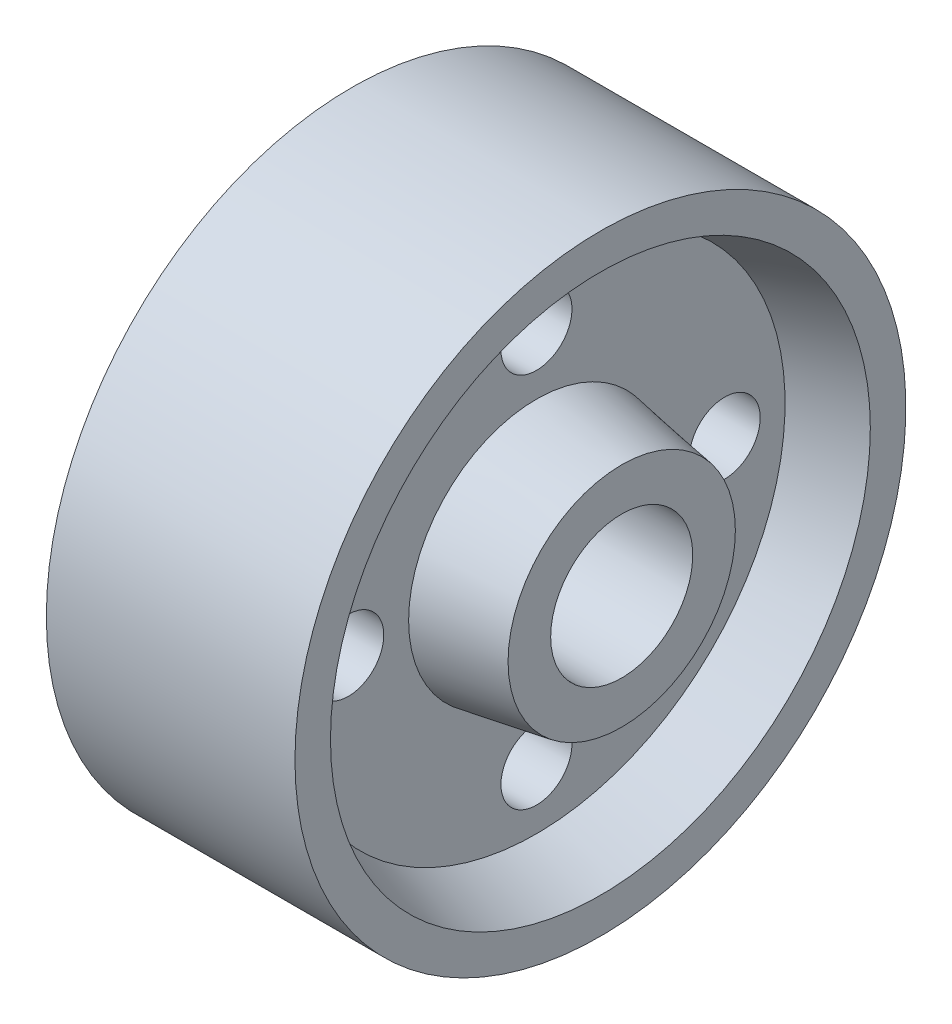
from build123d import *

# Parameters (mm, degrees)
SKETCH3_R          = 5
CUT_EXTRUDE1_DEPTH = 42
SKETCH4_R          = 10
CUT_EXTRUDE2_DEPTH = 42


with BuildPart() as part:
    # Sketch1 → Revolve2 (revolve)
    with BuildSketch(Plane(origin=(0, 0, 0), x_dir=(1, 0, 0), z_dir=(0, 1, 0))):
        Polygon((0, 0), (0, 16), (12, 18), (12, 35), (3, 38), (3, 43), (38, 43), (38, 38), (29, 35), (29, 18), (41, 16), (41, 0), align=None)
    revolve(axis=Axis((0, 0, 0), (1, 0, 0)))

    # Sketch3 → Cut-Extrude1 (cut, through all)
    with BuildSketch(Plane.ZY):
        with Locations((0, 26.499097724)):
            Circle(SKETCH3_R)
        with Locations((26.499097724, 0)):
            Circle(SKETCH3_R)
        with Locations((0, -26.499097724)):
            Circle(SKETCH3_R)
        with Locations((-26.499097724, 0)):
            Circle(SKETCH3_R)
    extrude(amount=-CUT_EXTRUDE1_DEPTH, mode=Mode.SUBTRACT)

    # Sketch4 → Cut-Extrude2 (cut, through all)
    with BuildSketch(Plane.ZY):
        Circle(SKETCH4_R)
    extrude(amount=-CUT_EXTRUDE2_DEPTH, mode=Mode.SUBTRACT)


solid = part.part
